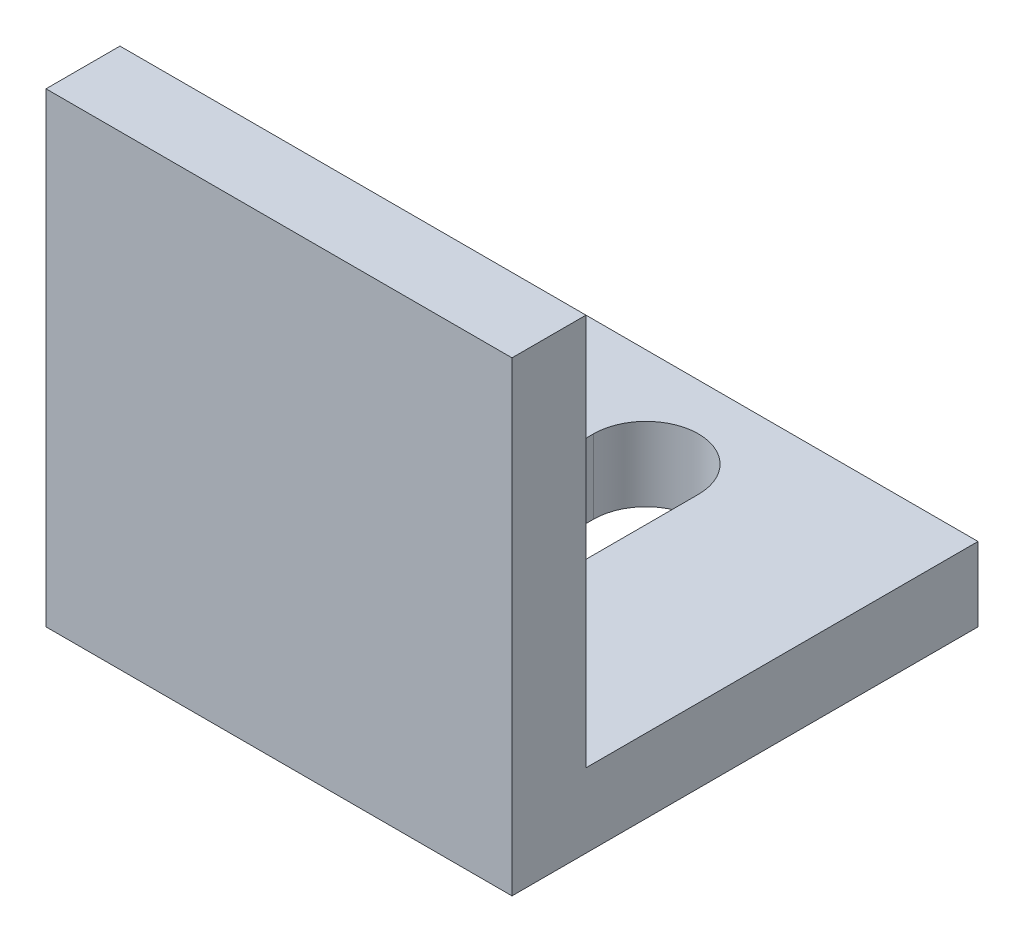
from build123d import *

# Parameters (mm, degrees)
BOSS_EXTRUDE1_DEPTH = 20
CUT_EXTRUDE1_DEPTH  = 21


with BuildPart() as part:
    # Sketch1 → Boss-Extrude1 (new body)
    with BuildSketch(Plane(origin=(0, 0, 0), x_dir=(0, 0, -1), z_dir=(1, 0, 0))):
        Polygon((0, 0), (0, 20), (3.175, 20), (3.175, 3.175), (20, 3.175), (20, 0), align=None)
    extrude(amount=BOSS_EXTRUDE1_DEPTH)

    # Sketch2 → Cut-Extrude1 (cut, through all)
    with BuildSketch(Plane(origin=(0, 0, 0), x_dir=(-1, 0, 0), z_dir=(0, -1, 0))):
        with BuildLine():
            Line((-7.75, 15.75), (-7.75, 5.75))
            ThreePointArc((-7.75, 5.75), (-10, 3.5), (-12.25, 5.75))
            Line((-12.25, 5.75), (-12.25, 15.75))
            ThreePointArc((-12.25, 15.75), (-10, 18), (-7.75, 15.75))
        make_face()
    extrude(amount=-CUT_EXTRUDE1_DEPTH, mode=Mode.SUBTRACT)


solid = part.part
